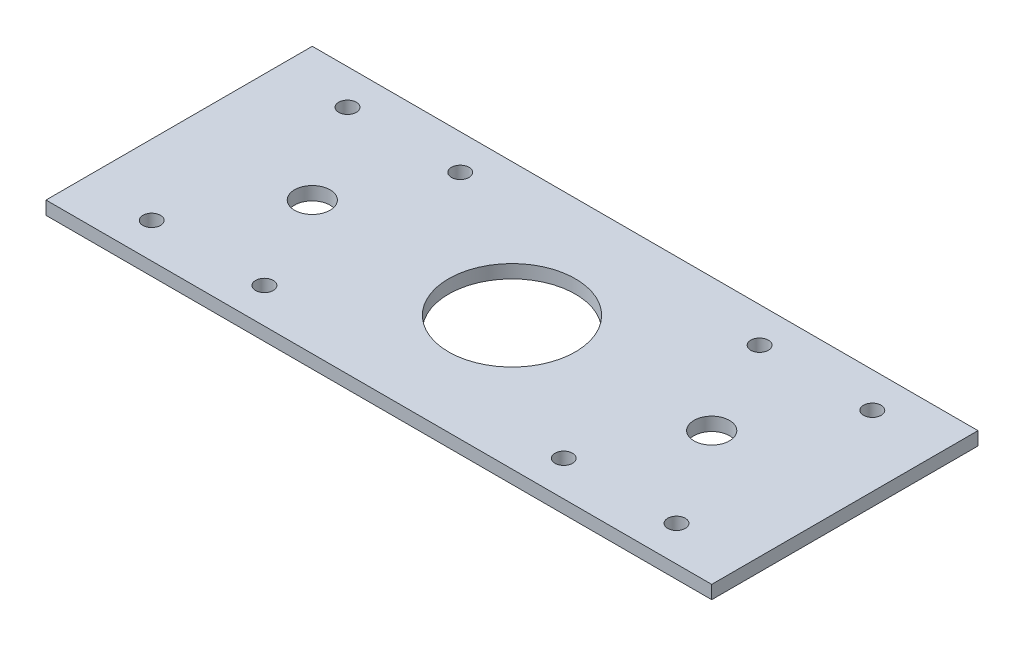
from build123d import *

# Parameters (mm, degrees)
SKETCH1_W           = 150
SKETCH1_H           = 60
BOSS_EXTRUDE1_DEPTH = 3
SKETCH2_R           = 14.2875
SKETCH2_R_2         = 1.984375
SKETCH2_R_3         = 4
CUT_EXTRUDE2_DEPTH  = 4


with BuildPart() as part:
    # Sketch1 → Boss-Extrude1 (new body)
    with BuildSketch(Plane(origin=(0, 0, 0), x_dir=(1, 0, 0), z_dir=(0, 1, 0))):
        Rectangle(SKETCH1_W, SKETCH1_H)
    extrude(amount=BOSS_EXTRUDE1_DEPTH)

    # Sketch2 → Cut-Extrude2 (cut, through all)
    with BuildSketch(Plane(origin=(0, 3, 0), x_dir=(1, 0, 0), z_dir=(0, 1, 0))):
        Circle(SKETCH2_R)
        with Locations((59.125, 22.0625)):
            Circle(SKETCH2_R_2)
        with Locations((33.725, 22.0625)):
            Circle(SKETCH2_R_2)
        with Locations((33.725, -22.0625)):
            Circle(SKETCH2_R_2)
        with Locations((59.125, -22.0625)):
            Circle(SKETCH2_R_2)
        with Locations((-33.725, 22.0625)):
            Circle(SKETCH2_R_2)
        with Locations((-59.125, 22.0625)):
            Circle(SKETCH2_R_2)
        with Locations((-59.125, -22.0625)):
            Circle(SKETCH2_R_2)
        with Locations((-33.725, -22.0625)):
            Circle(SKETCH2_R_2)
        with Locations((45, 0)):
            Circle(SKETCH2_R_3)
        with Locations((-45, 0)):
            Circle(SKETCH2_R_3)
    extrude(amount=-CUT_EXTRUDE2_DEPTH, mode=Mode.SUBTRACT)


solid = part.part
